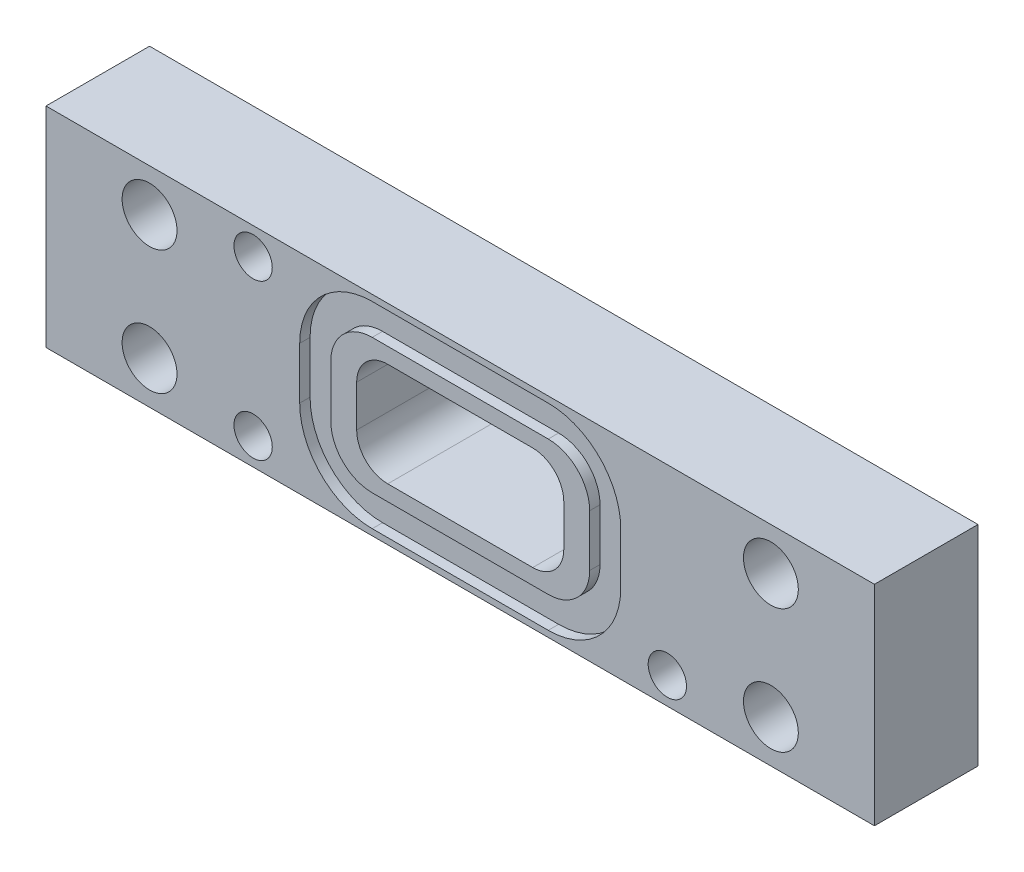
from build123d import *

# Parameters (mm, degrees)
SKIZZE1_W                        = 80
SKIZZE1_H                        = 20.2
SKIZZE1_R                        = 2.65
SKIZZE1_W_2                      = 20
SKIZZE1_H_2                      = 10
AUFSATZ_LINEAR_AUSTRAGEN1_DEPTH  = 10
VERRUNDUNG1_R                    = 3
F_3_7_3_7_DURCHMESSER_BOHRUNG1_D = 3.7
SCHNITT_LINEAR_AUSTRAGEN1_DEPTH  = 1


with BuildPart() as part:
    # Skizze1 → Aufsatz-Linear austragen1 (new body)
    with BuildSketch(Plane.XY):
        with Locations((40, 10.1)):
            Rectangle(SKIZZE1_W, SKIZZE1_H)
        with Locations((10, 16.1)):
            Circle(SKIZZE1_R, mode=Mode.SUBTRACT)
        with Locations((10, 4.1)):
            Circle(SKIZZE1_R, mode=Mode.SUBTRACT)
        with Locations((70, 16.1)):
            Circle(SKIZZE1_R, mode=Mode.SUBTRACT)
        with Locations((70, 4.1)):
            Circle(SKIZZE1_R, mode=Mode.SUBTRACT)
        with Locations((40, 10.1)):
            Rectangle(SKIZZE1_W_2, SKIZZE1_H_2, mode=Mode.SUBTRACT)
    extrude(amount=AUFSATZ_LINEAR_AUSTRAGEN1_DEPTH)

    # Verrundung1
    verrundung1_edges = [part.edges().sort_by_distance(p)[0] for p in [
        (50, 5.1, 5),
        (50, 15.1, 5),
        (30, 15.1, 5),
        (30, 5.1, 5),
    ]]
    fillet(verrundung1_edges, radius=VERRUNDUNG1_R)

    # Ø3.7 (3.7) Durchmesser Bohrung1 (through all)
    with Locations(Plane.XY.offset(10)):
        with Locations((20, 17.6), (20, 2.6), (60, 2.6)):
            Hole(F_3_7_3_7_DURCHMESSER_BOHRUNG1_D / 2)

    # Skizze7 → Schnitt-Linear austragen1 (cut)
    with BuildSketch(Plane.XY.offset(10)):
        with BuildLine():
            Line((24.5, 12.6), (24.5, 7.6))
            ThreePointArc((24.5, 7.6), (26.550252532, 2.650252532), (31.5, 0.6))
            Line((31.5, 0.6), (48.5, 0.6))
            ThreePointArc((48.5, 0.6), (53.449747468, 2.650252532), (55.5, 7.6))
            Line((55.5, 7.6), (55.5, 12.6))
            ThreePointArc((55.5, 12.6), (53.449747468, 17.549747468), (48.5, 19.6))
            Line((48.5, 19.6), (31.5, 19.6))
            ThreePointArc((31.5, 19.6), (26.550252532, 17.549747468), (24.5, 12.6))
        make_face()
        with BuildLine():
            Line((31.5, 16.6), (48.5, 16.6))
            ThreePointArc((48.5, 16.6), (51.328427125, 15.428427125), (52.5, 12.6))
            Line((52.5, 12.6), (52.5, 7.6))
            ThreePointArc((52.5, 7.6), (51.328427125, 4.771572875), (48.5, 3.6))
            Line((48.5, 3.6), (31.5, 3.6))
            ThreePointArc((31.5, 3.6), (28.671572875, 4.771572875), (27.5, 7.6))
            Line((27.5, 7.6), (27.5, 12.6))
            ThreePointArc((27.5, 12.6), (28.671572875, 15.428427125), (31.5, 16.6))
        make_face(mode=Mode.SUBTRACT)
    extrude(amount=-SCHNITT_LINEAR_AUSTRAGEN1_DEPTH, mode=Mode.SUBTRACT)


solid = part.part
